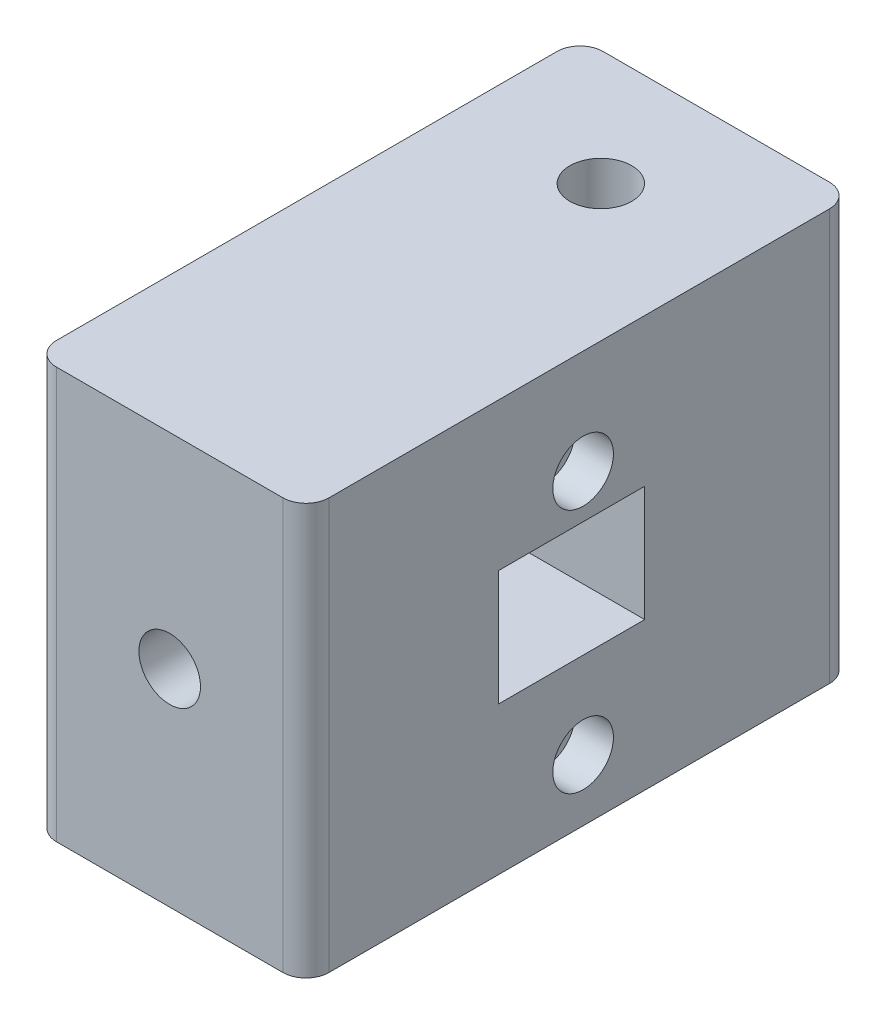
from build123d import *

# Parameters (mm, degrees)
SKETCH1_W           = 44.958
SKETCH1_H           = 67.818
BOSS_EXTRUDE1_DEPTH = 90.17
SKETCH2_R           = 5
CUT_EXTRUDE1_DEPTH  = 6.35
SKETCH3_R           = 4.064
CUT_EXTRUDE2_DEPTH  = 68.818
SKETCH4_R           = 5.1
CUT_EXTRUDE3_DEPTH  = 15.24
SKETCH5_R           = 5.08
CUT_EXTRUDE4_DEPTH  = 50.8
SKETCH6_W           = 24.13
SKETCH6_H           = 19.05
CUT_EXTRUDE5_DEPTH  = 34.29
FILLET1_R           = 3.81


with BuildPart() as part:
    # Sketch1 → Boss-Extrude1 (new body)
    with BuildSketch(Plane.XY):
        with Locations((22.479, 33.909)):
            Rectangle(SKETCH1_W, SKETCH1_H)
    extrude(amount=BOSS_EXTRUDE1_DEPTH)

    # Sketch2 → Cut-Extrude1 (cut)
    with BuildSketch(Plane(origin=(44.958, 0, 0), x_dir=(0, 0, -1), z_dir=(1, 0, 0))):
        with Locations((-44.45, 50.66)):
            Circle(SKETCH2_R)
        with Locations((-44.45, 10.16)):
            Circle(SKETCH2_R)
    extrude(amount=-CUT_EXTRUDE1_DEPTH, mode=Mode.SUBTRACT)

    # Sketch3 → Cut-Extrude2 (cut, through all)
    with BuildSketch(Plane(origin=(0, 67.818, 0), x_dir=(1, 0, 0), z_dir=(0, 1, 0))):
        with Locations((22.479, -19.05)):
            Circle(SKETCH3_R)
    extrude(amount=-CUT_EXTRUDE2_DEPTH, mode=Mode.SUBTRACT)

    # Sketch4 → Cut-Extrude3 (cut)
    with BuildSketch(Plane(origin=(0, 67.818, 0), x_dir=(1, 0, 0), z_dir=(0, 1, 0))):
        with Locations((22.479, -19.05)):
            Circle(SKETCH4_R)
    extrude(amount=-CUT_EXTRUDE3_DEPTH, mode=Mode.SUBTRACT)

    # Sketch5 → Cut-Extrude4 (cut)
    with BuildSketch(Plane.XY.offset(90.17)):
        with Locations((22.479, 34.036)):
            Circle(SKETCH5_R)
    extrude(amount=-CUT_EXTRUDE4_DEPTH, mode=Mode.SUBTRACT)

    # Sketch6 → Cut-Extrude5 (cut)
    with BuildSketch(Plane(origin=(44.958, 0, 0), x_dir=(0, 0, -1), z_dir=(1, 0, 0))):
        with Locations((-46.355, 33.909)):
            Rectangle(SKETCH6_W, SKETCH6_H)
    extrude(amount=-CUT_EXTRUDE5_DEPTH, mode=Mode.SUBTRACT)

    # Fillet1
    fillet1_edges = [part.edges().sort_by_distance(p)[0] for p in [
        (44.958, 33.909, 90.17),
        (0, 33.909, 90.17),
        (44.958, 33.909, 0),
        (0, 33.909, 0),
    ]]
    fillet(fillet1_edges, radius=FILLET1_R)


solid = part.part
